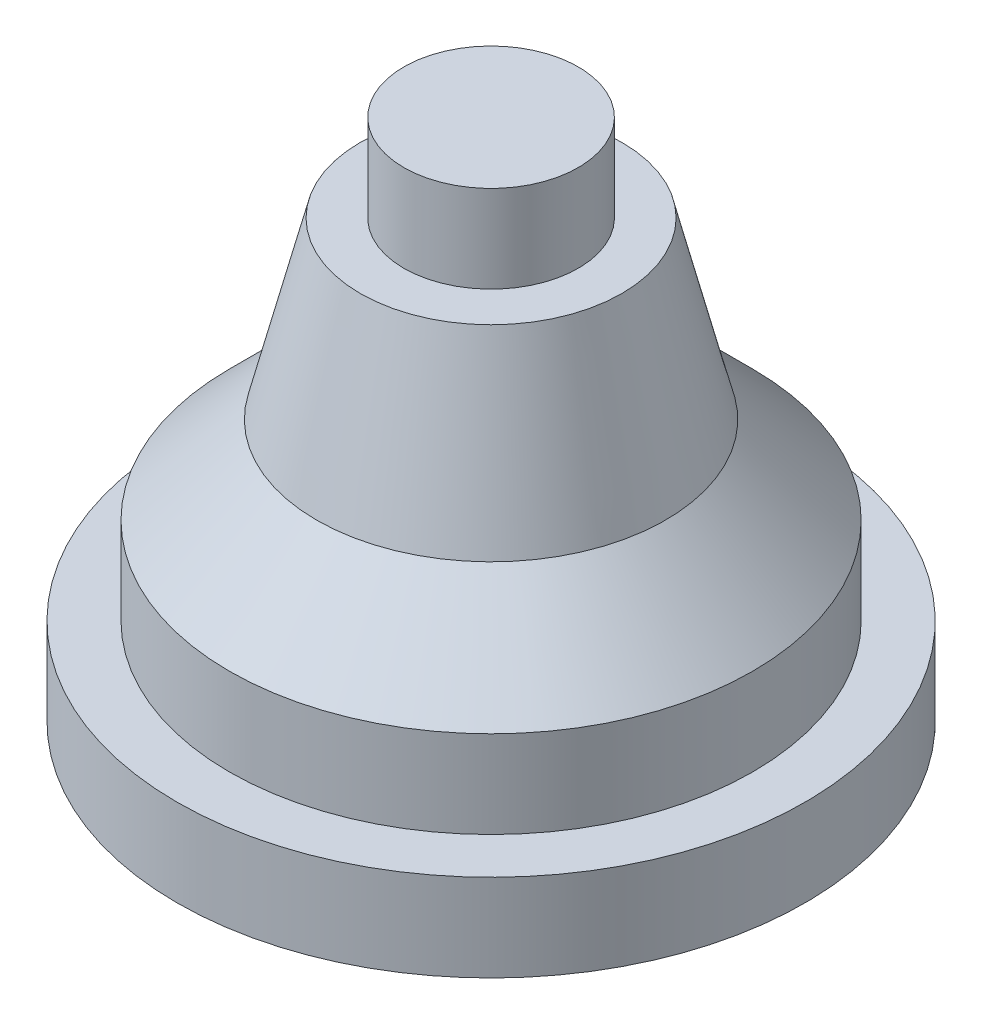
from build123d import *


with BuildPart() as part:
    # Esboço1 → Revolução1 (revolve)
    with BuildSketch(Plane.XY, mode=Mode.PRIVATE) as revolu_o1_sk:
        Polygon((0, 75), (25, 75), (25, 50), (37.5, 50), (50, 0), (75, -25), (75, -50), (90, -50), (90, -75), (0, -75), align=None)
    revolve(revolu_o1_sk.sketch.rotate(Axis((0, 54.909632035, 0), (0, -1, 0)), 90), axis=Axis((0, 54.909632035, 0), (0, -1, 0)))  # turned: the seam where the file's is


solid = part.part
